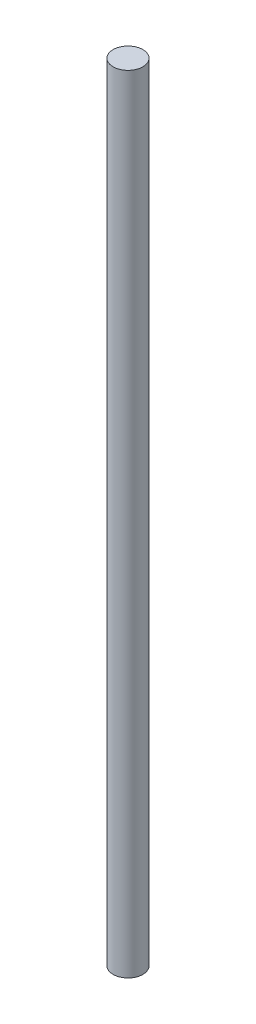
from build123d import *

# Parameters (mm, degrees)
SKETCH1_R           = 5.5
BOSS_EXTRUDE1_DEPTH = 290


with BuildPart() as part:
    # Sketch1 → Boss-Extrude1 (new body)
    with BuildSketch(Plane(origin=(0, 0, 0), x_dir=(1, 0, 0), z_dir=(0, 1, 0))):
        Circle(SKETCH1_R)
    extrude(amount=BOSS_EXTRUDE1_DEPTH)


solid = part.part
